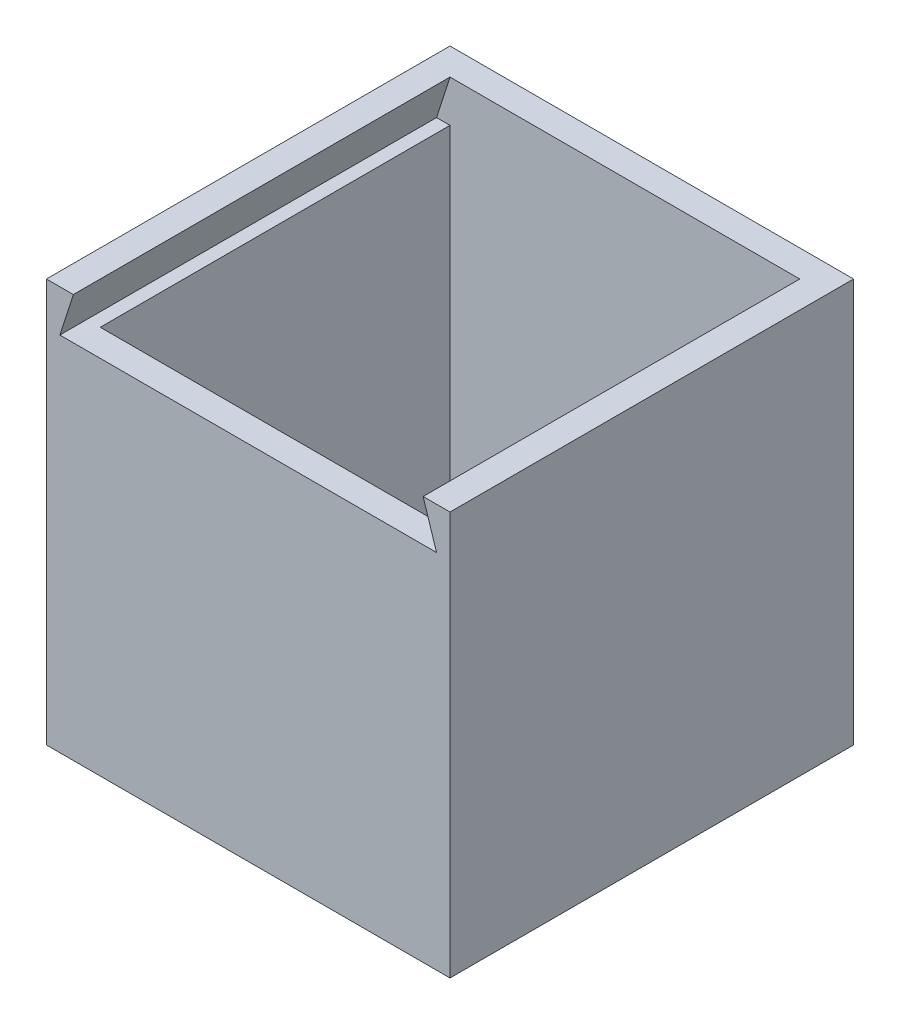
from build123d import *

# Parameters (mm, degrees)
SKETCH1_W           = 95.25
SKETCH1_H           = 95.25
BOSS_EXTRUDE1_DEPTH = 95.25
SHELL1_T            = -6.35
CUT_EXTRUDE1_DEPTH  = 88.9


with BuildPart() as part:
    # Sketch1 → Boss-Extrude1 (new body)
    with BuildSketch(Plane(origin=(0, 0, 0), x_dir=(1, 0, 0), z_dir=(0, 1, 0))):
        with Locations((-0.25880421, -21.492307692)):
            Rectangle(SKETCH1_W, SKETCH1_H)
    extrude(amount=BOSS_EXTRUDE1_DEPTH)

    # Shell1
    shell1_openings = [part.faces().sort_by_distance(p)[0] for p in [
        (-0.25880421, 95.25, 21.492307692),
    ]]
    offset(amount=SHELL1_T, openings=shell1_openings, kind=Kind.INTERSECTION)

    # Sketch2 → Cut-Extrude1 (cut)
    with BuildSketch(Plane.XY.offset(69.117307692)):
        Polygon((41.01619579, 95.25), (-41.53380421, 95.25), (-44.70880421, 85.381498792), (44.19119579, 85.381498792), align=None)
    extrude(amount=-CUT_EXTRUDE1_DEPTH, mode=Mode.SUBTRACT)


solid = part.part
